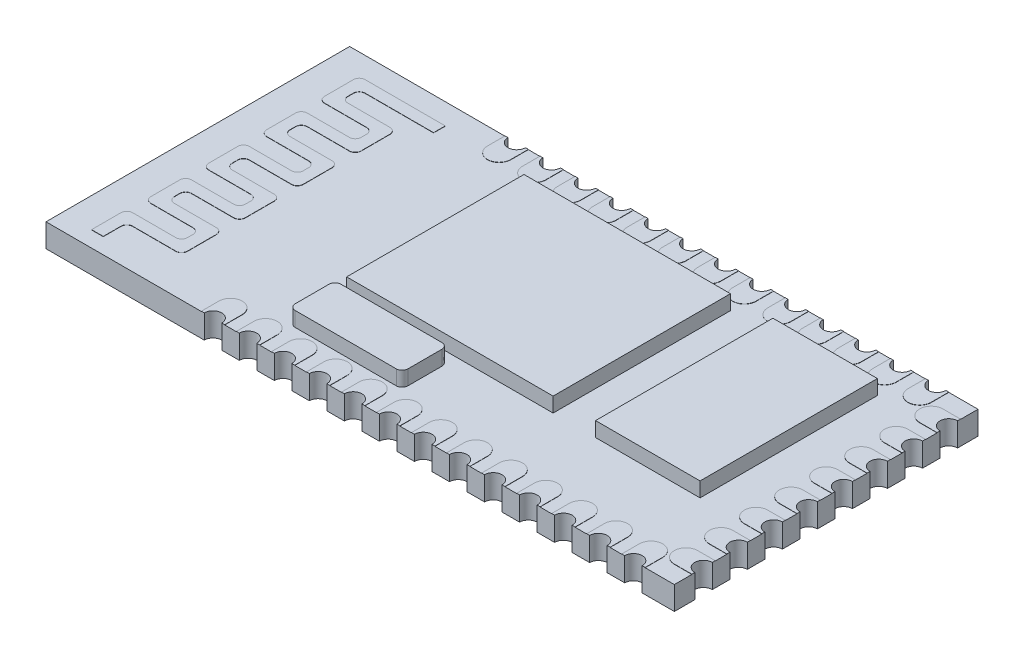
from build123d import *

# Parameters (mm, degrees)
SKETCH1_W           = 26.9
SKETCH1_H           = 13
BOSS_EXTRUDE1_DEPTH = 1
SKETCH2_W           = 4.474027776
SKETCH2_H           = 7.592289559
SKETCH2_W_2         = 8.839594273
BOSS_EXTRUDE2_DEPTH = 0.63
BOSS_EXTRUDE3_DEPTH = 0.01
BOSS_EXTRUDE4_DEPTH = 0.63
BOSS_EXTRUDE5_DEPTH = 0.01
SKETCH7_W           = 22.420690482
SKETCH7_H           = 1.871477004
CUT_EXTRUDE1_DEPTH  = 2.01
SKETCH8_R           = 0.375
CUT_EXTRUDE2_DEPTH  = 2.01
LPATTERN1_COUNT     = 13
LPATTERN1_PITCH     = 1.5
SKETCH9_R           = 0.375
CUT_EXTRUDE3_DEPTH  = 2.01
LPATTERN2_COUNT     = 8
LPATTERN2_PITCH     = 1.5
SCALE1_SCALE        = 1.769


with BuildPart() as part:
    # Sketch1 → Boss-Extrude1 (new body)
    with BuildSketch(Plane(origin=(0, 0, 0), x_dir=(1, 0, 0), z_dir=(0, 1, 0))):
        with Locations((13.45, 6.5)):
            Rectangle(SKETCH1_W, SKETCH1_H)
    extrude(amount=BOSS_EXTRUDE1_DEPTH)

    # Sketch2 → Boss-Extrude2 (add)
    with BuildSketch(Plane(origin=(0, 1, 0), x_dir=(1, 0, 0), z_dir=(0, 1, 0))):
        with Locations((22.000611186, 7.559584322)):
            Rectangle(SKETCH2_W, SKETCH2_H)
        with Locations((13.527073731, 7.559584322)):
            Rectangle(SKETCH2_W_2, SKETCH2_H)
    extrude(amount=BOSS_EXTRUDE2_DEPTH)

    # Sketch3 → Boss-Extrude3 (add)
    with BuildSketch(Plane(origin=(0, 1, 0), x_dir=(1, 0, 0), z_dir=(0, 1, 0))):
        with BuildLine():
            Line((5.001748059, 12.091352807), (1.569925159, 12.091352807))
            ThreePointArc((1.569925159, 12.091352807), (1.393148464, 12.018129502), (1.319925159, 11.841352807))
            Line((1.319925159, 11.841352807), (1.319925159, 10.602651625))
            ThreePointArc((1.319925159, 10.602651625), (1.393148464, 10.42587493), (1.569925159, 10.352651625))
            Line((1.569925159, 10.352651625), (3.374727347, 10.352651625))
            ThreePointArc((3.374727347, 10.352651625), (3.551504042, 10.27942832), (3.624727347, 10.102651625))
            Line((3.624727347, 10.102651625), (3.624727347, 9.863950443))
            ThreePointArc((3.624727347, 9.863950443), (3.551504042, 9.687173748), (3.374727347, 9.613950443))
            Line((3.374727347, 9.613950443), (1.569925159, 9.613950443))
            ThreePointArc((1.569925159, 9.613950443), (1.393148464, 9.540727138), (1.319925159, 9.363950443))
            Line((1.319925159, 9.363950443), (1.319925159, 8.125249261))
            ThreePointArc((1.319925159, 8.125249261), (1.393148464, 7.948472566), (1.569925159, 7.875249261))
            Line((1.569925159, 7.875249261), (3.374727347, 7.875249261))
            ThreePointArc((3.374727347, 7.875249261), (3.551504042, 7.802025956), (3.624727347, 7.625249261))
            Line((3.624727347, 7.625249261), (3.624727347, 7.386548079))
            ThreePointArc((3.624727347, 7.386548079), (3.551504042, 7.209771384), (3.374727347, 7.136548079))
            Line((3.374727347, 7.136548079), (1.569925159, 7.136548079))
            ThreePointArc((1.569925159, 7.136548079), (1.393148464, 7.063324774), (1.319925159, 6.886548079))
            Line((1.319925159, 6.886548079), (1.319925159, 5.647846897))
            ThreePointArc((1.319925159, 5.647846897), (1.393148464, 5.471070202), (1.569925159, 5.397846897))
            Line((1.569925159, 5.397846897), (3.374727347, 5.397846897))
            ThreePointArc((3.374727347, 5.397846897), (3.551504042, 5.324623592), (3.624727347, 5.147846897))
            Line((3.624727347, 5.147846897), (3.624727347, 4.909145715))
            ThreePointArc((3.624727347, 4.909145715), (3.551504042, 4.732369019), (3.374727347, 4.659145715))
            Line((3.374727347, 4.659145715), (1.569925159, 4.659145715))
            ThreePointArc((1.569925159, 4.659145715), (1.393148464, 4.58592241), (1.319925159, 4.409145715))
            Line((1.319925159, 4.409145715), (1.319925159, 3.170444533))
            ThreePointArc((1.319925159, 3.170444533), (1.393148464, 2.993667837), (1.569925159, 2.920444533))
            Line((1.569925159, 2.920444533), (3.374727347, 2.920444533))
            ThreePointArc((3.374727347, 2.920444533), (3.551504042, 2.847221228), (3.624727347, 2.670444533))
            Line((3.624727347, 2.670444533), (3.624727347, 2.431743351))
            ThreePointArc((3.624727347, 2.431743351), (3.551504042, 2.254966655), (3.374727347, 2.181743351))
            Line((3.374727347, 2.181743351), (1.527027373, 2.181743351))
            ThreePointArc((1.527027373, 2.181743351), (1.350250678, 2.108520046), (1.277027373, 1.931743351))
            Line((1.277027373, 1.931743351), (1.277027373, 0.673866206))
            Line((1.277027373, 0.673866206), (1.777027373, 0.673866206))
            Line((1.777027373, 0.673866206), (1.777027373, 1.431743351))
            ThreePointArc((1.777027373, 1.431743351), (1.850250678, 1.608520046), (2.027027373, 1.681743351))
            Line((2.027027373, 1.681743351), (3.874727347, 1.681743351))
            ThreePointArc((3.874727347, 1.681743351), (4.051504042, 1.754966655), (4.124727347, 1.931743351))
            Line((4.124727347, 1.931743351), (4.124727347, 3.170444533))
            ThreePointArc((4.124727347, 3.170444533), (4.051504042, 3.347221228), (3.874727347, 3.420444533))
            Line((3.874727347, 3.420444533), (2.069925159, 3.420444533))
            ThreePointArc((2.069925159, 3.420444533), (1.893148464, 3.493667837), (1.819925159, 3.670444533))
            Line((1.819925159, 3.670444533), (1.819925159, 3.909145715))
            ThreePointArc((1.819925159, 3.909145715), (1.893148464, 4.08592241), (2.069925159, 4.159145715))
            Line((2.069925159, 4.159145715), (3.874727347, 4.159145715))
            ThreePointArc((3.874727347, 4.159145715), (4.051504042, 4.232369019), (4.124727347, 4.409145715))
            Line((4.124727347, 4.409145715), (4.124727347, 5.647846897))
            ThreePointArc((4.124727347, 5.647846897), (4.051504042, 5.824623592), (3.874727347, 5.897846897))
            Line((3.874727347, 5.897846897), (2.069925159, 5.897846897))
            ThreePointArc((2.069925159, 5.897846897), (1.893148464, 5.971070202), (1.819925159, 6.147846897))
            Line((1.819925159, 6.147846897), (1.819925159, 6.386548079))
            ThreePointArc((1.819925159, 6.386548079), (1.893148464, 6.563324774), (2.069925159, 6.636548079))
            Line((2.069925159, 6.636548079), (3.874727347, 6.636548079))
            ThreePointArc((3.874727347, 6.636548079), (4.051504042, 6.709771384), (4.124727347, 6.886548079))
            Line((4.124727347, 6.886548079), (4.124727347, 8.125249261))
            ThreePointArc((4.124727347, 8.125249261), (4.051504042, 8.302025956), (3.874727347, 8.375249261))
            Line((3.874727347, 8.375249261), (2.069925159, 8.375249261))
            ThreePointArc((2.069925159, 8.375249261), (1.893148464, 8.448472566), (1.819925159, 8.625249261))
            Line((1.819925159, 8.625249261), (1.819925159, 8.863950443))
            ThreePointArc((1.819925159, 8.863950443), (1.893148464, 9.040727138), (2.069925159, 9.113950443))
            Line((2.069925159, 9.113950443), (3.874727347, 9.113950443))
            ThreePointArc((3.874727347, 9.113950443), (4.051504042, 9.187173748), (4.124727347, 9.363950443))
            Line((4.124727347, 9.363950443), (4.124727347, 10.602651625))
            ThreePointArc((4.124727347, 10.602651625), (4.051504042, 10.77942832), (3.874727347, 10.852651625))
            Line((3.874727347, 10.852651625), (2.069925159, 10.852651625))
            ThreePointArc((2.069925159, 10.852651625), (1.893148464, 10.92587493), (1.819925159, 11.102651625))
            Line((1.819925159, 11.102651625), (1.819925159, 11.341352807))
            ThreePointArc((1.819925159, 11.341352807), (1.893148464, 11.518129502), (2.069925159, 11.591352807))
            Line((2.069925159, 11.591352807), (5.001748059, 11.591352807))
            Line((5.001748059, 11.591352807), (5.001748059, 12.091352807))
        make_face()
    extrude(amount=BOSS_EXTRUDE3_DEPTH)

    # Sketch4 → Boss-Extrude4 (add)
    with BuildSketch(Plane(origin=(0, 1, 0), x_dir=(1, 0, 0), z_dir=(0, 1, 0))):
        with BuildLine():
            Line((9.253087544, 3.367848777), (13.579614478, 3.367848777))
            ThreePointArc((13.579614478, 3.367848777), (13.756391173, 3.294625473), (13.829614478, 3.117848777))
            Line((13.829614478, 3.117848777), (13.829614478, 1.665545748))
            ThreePointArc((13.829614478, 1.665545748), (13.756391173, 1.488769052), (13.579614478, 1.415545748))
            Line((13.579614478, 1.415545748), (9.253087544, 1.415545748))
            ThreePointArc((9.253087544, 1.415545748), (9.076310848, 1.488769052), (9.003087544, 1.665545748))
            Line((9.003087544, 1.665545748), (9.003087544, 3.117848777))
            ThreePointArc((9.003087544, 3.117848777), (9.076310848, 3.294625473), (9.253087544, 3.367848777))
        make_face()
    extrude(amount=BOSS_EXTRUDE4_DEPTH)

    # Sketch5 → Boss-Extrude5 (add)
    with BuildSketch(Plane(origin=(0, 1, 0), x_dir=(1, 0, 0), z_dir=(0, 1, 0))):
        with BuildLine():
            Line((26.15, 12.25), (28.15, 12.25))
            ThreePointArc((28.15, 12.25), (28.65, 11.75), (28.15, 11.25))
            Line((28.15, 11.25), (26.15, 11.25))
            ThreePointArc((26.15, 11.25), (25.65, 11.75), (26.15, 12.25))
        make_face()
        with BuildLine():
            Line((26.15, 10.75), (28.15, 10.75))
            ThreePointArc((28.15, 10.75), (28.65, 10.25), (28.15, 9.75))
            Line((28.15, 9.75), (26.15, 9.75))
            ThreePointArc((26.15, 9.75), (25.65, 10.25), (26.15, 10.75))
        make_face()
        with BuildLine():
            Line((26.15, 9.25), (28.15, 9.25))
            ThreePointArc((28.15, 9.25), (28.65, 8.75), (28.15, 8.25))
            Line((28.15, 8.25), (26.15, 8.25))
            ThreePointArc((26.15, 8.25), (25.65, 8.75), (26.15, 9.25))
        make_face()
        with BuildLine():
            Line((26.15, 7.75), (28.15, 7.75))
            ThreePointArc((28.15, 7.75), (28.65, 7.25), (28.15, 6.75))
            Line((28.15, 6.75), (26.15, 6.75))
            ThreePointArc((26.15, 6.75), (25.65, 7.25), (26.15, 7.75))
        make_face()
        with BuildLine():
            Line((26.15, 6.25), (28.15, 6.25))
            ThreePointArc((28.15, 6.25), (28.65, 5.75), (28.15, 5.25))
            Line((28.15, 5.25), (26.15, 5.25))
            ThreePointArc((26.15, 5.25), (25.65, 5.75), (26.15, 6.25))
        make_face()
        with BuildLine():
            Line((26.15, 4.75), (28.15, 4.75))
            ThreePointArc((28.15, 4.75), (28.65, 4.25), (28.15, 3.75))
            Line((28.15, 3.75), (26.15, 3.75))
            ThreePointArc((26.15, 3.75), (25.65, 4.25), (26.15, 4.75))
        make_face()
        with BuildLine():
            Line((26.15, 3.25), (28.15, 3.25))
            ThreePointArc((28.15, 3.25), (28.65, 2.75), (28.15, 2.25))
            Line((28.15, 2.25), (26.15, 2.25))
            ThreePointArc((26.15, 2.25), (25.65, 2.75), (26.15, 3.25))
        make_face()
        with BuildLine():
            Line((26.15, 1.75), (28.15, 1.75))
            ThreePointArc((28.15, 1.75), (28.65, 1.25), (28.15, 0.75))
            Line((28.15, 0.75), (26.15, 0.75))
            ThreePointArc((26.15, 0.75), (25.65, 1.25), (26.15, 1.75))
        make_face()
        with BuildLine():
            Line((24.65, 12.25), (24.65, 14.25))
            ThreePointArc((24.65, 14.25), (25.15, 14.75), (25.65, 14.25))
            Line((25.65, 14.25), (25.65, 12.25))
            ThreePointArc((25.65, 12.25), (25.15, 11.75), (24.65, 12.25))
        make_face()
        with BuildLine():
            Line((23.15, 12.25), (23.15, 14.25))
            ThreePointArc((23.15, 14.25), (23.65, 14.75), (24.15, 14.25))
            Line((24.15, 14.25), (24.15, 12.25))
            ThreePointArc((24.15, 12.25), (23.65, 11.75), (23.15, 12.25))
        make_face()
        with BuildLine():
            Line((21.65, 12.25), (21.65, 14.25))
            ThreePointArc((21.65, 14.25), (22.15, 14.75), (22.65, 14.25))
            Line((22.65, 14.25), (22.65, 12.25))
            ThreePointArc((22.65, 12.25), (22.15, 11.75), (21.65, 12.25))
        make_face()
        with BuildLine():
            Line((20.15, 12.25), (20.15, 14.25))
            ThreePointArc((20.15, 14.25), (20.65, 14.75), (21.15, 14.25))
            Line((21.15, 14.25), (21.15, 12.25))
            ThreePointArc((21.15, 12.25), (20.65, 11.75), (20.15, 12.25))
        make_face()
        with BuildLine():
            Line((18.65, 12.25), (18.65, 14.25))
            ThreePointArc((18.65, 14.25), (19.15, 14.75), (19.65, 14.25))
            Line((19.65, 14.25), (19.65, 12.25))
            ThreePointArc((19.65, 12.25), (19.15, 11.75), (18.65, 12.25))
        make_face()
        with BuildLine():
            Line((17.15, 12.25), (17.15, 14.25))
            ThreePointArc((17.15, 14.25), (17.65, 14.75), (18.15, 14.25))
            Line((18.15, 14.25), (18.15, 12.25))
            ThreePointArc((18.15, 12.25), (17.65, 11.75), (17.15, 12.25))
        make_face()
        with BuildLine():
            Line((15.65, 12.25), (15.65, 14.25))
            ThreePointArc((15.65, 14.25), (16.15, 14.75), (16.65, 14.25))
            Line((16.65, 14.25), (16.65, 12.25))
            ThreePointArc((16.65, 12.25), (16.15, 11.75), (15.65, 12.25))
        make_face()
        with BuildLine():
            Line((14.15, 12.25), (14.15, 14.25))
            ThreePointArc((14.15, 14.25), (14.65, 14.75), (15.15, 14.25))
            Line((15.15, 14.25), (15.15, 12.25))
            ThreePointArc((15.15, 12.25), (14.65, 11.75), (14.15, 12.25))
        make_face()
        with BuildLine():
            Line((12.65, 12.25), (12.65, 14.25))
            ThreePointArc((12.65, 14.25), (13.15, 14.75), (13.65, 14.25))
            Line((13.65, 14.25), (13.65, 12.25))
            ThreePointArc((13.65, 12.25), (13.15, 11.75), (12.65, 12.25))
        make_face()
        with BuildLine():
            Line((11.15, 12.25), (11.15, 14.25))
            ThreePointArc((11.15, 14.25), (11.65, 14.75), (12.15, 14.25))
            Line((12.15, 14.25), (12.15, 12.25))
            ThreePointArc((12.15, 12.25), (11.65, 11.75), (11.15, 12.25))
        make_face()
        with BuildLine():
            Line((9.65, 12.25), (9.65, 14.25))
            ThreePointArc((9.65, 14.25), (10.15, 14.75), (10.65, 14.25))
            Line((10.65, 14.25), (10.65, 12.25))
            ThreePointArc((10.65, 12.25), (10.15, 11.75), (9.65, 12.25))
        make_face()
        with BuildLine():
            Line((8.15, 12.25), (8.15, 14.25))
            ThreePointArc((8.15, 14.25), (8.65, 14.75), (9.15, 14.25))
            Line((9.15, 14.25), (9.15, 12.25))
            ThreePointArc((9.15, 12.25), (8.65, 11.75), (8.15, 12.25))
        make_face()
        with BuildLine():
            Line((6.65, 12.25), (6.65, 14.25))
            ThreePointArc((6.65, 14.25), (7.15, 14.75), (7.65, 14.25))
            Line((7.65, 14.25), (7.65, 12.25))
            ThreePointArc((7.65, 12.25), (7.15, 11.75), (6.65, 12.25))
        make_face()
        with BuildLine():
            Line((24.65, 0.75), (24.65, -1.25))
            ThreePointArc((24.65, -1.25), (25.15, -1.75), (25.65, -1.25))
            Line((25.65, -1.25), (25.65, 0.75))
            ThreePointArc((25.65, 0.75), (25.15, 1.25), (24.65, 0.75))
        make_face()
        with BuildLine():
            Line((23.15, 0.75), (23.15, -1.25))
            ThreePointArc((23.15, -1.25), (23.65, -1.75), (24.15, -1.25))
            Line((24.15, -1.25), (24.15, 0.75))
            ThreePointArc((24.15, 0.75), (23.65, 1.25), (23.15, 0.75))
        make_face()
        with BuildLine():
            Line((21.65, 0.75), (21.65, -1.25))
            ThreePointArc((21.65, -1.25), (22.15, -1.75), (22.65, -1.25))
            Line((22.65, -1.25), (22.65, 0.75))
            ThreePointArc((22.65, 0.75), (22.15, 1.25), (21.65, 0.75))
        make_face()
        with BuildLine():
            Line((20.15, 0.75), (20.15, -1.25))
            ThreePointArc((20.15, -1.25), (20.65, -1.75), (21.15, -1.25))
            Line((21.15, -1.25), (21.15, 0.75))
            ThreePointArc((21.15, 0.75), (20.65, 1.25), (20.15, 0.75))
        make_face()
        with BuildLine():
            Line((18.65, 0.75), (18.65, -1.25))
            ThreePointArc((18.65, -1.25), (19.15, -1.75), (19.65, -1.25))
            Line((19.65, -1.25), (19.65, 0.75))
            ThreePointArc((19.65, 0.75), (19.15, 1.25), (18.65, 0.75))
        make_face()
        with BuildLine():
            Line((17.15, 0.75), (17.15, -1.25))
            ThreePointArc((17.15, -1.25), (17.65, -1.75), (18.15, -1.25))
            Line((18.15, -1.25), (18.15, 0.75))
            ThreePointArc((18.15, 0.75), (17.65, 1.25), (17.15, 0.75))
        make_face()
        with BuildLine():
            Line((15.65, 0.75), (15.65, -1.25))
            ThreePointArc((15.65, -1.25), (16.15, -1.75), (16.65, -1.25))
            Line((16.65, -1.25), (16.65, 0.75))
            ThreePointArc((16.65, 0.75), (16.15, 1.25), (15.65, 0.75))
        make_face()
        with BuildLine():
            Line((14.15, 0.75), (14.15, -1.25))
            ThreePointArc((14.15, -1.25), (14.65, -1.75), (15.15, -1.25))
            Line((15.15, -1.25), (15.15, 0.75))
            ThreePointArc((15.15, 0.75), (14.65, 1.25), (14.15, 0.75))
        make_face()
        with BuildLine():
            Line((12.65, 0.75), (12.65, -1.25))
            ThreePointArc((12.65, -1.25), (13.15, -1.75), (13.65, -1.25))
            Line((13.65, -1.25), (13.65, 0.75))
            ThreePointArc((13.65, 0.75), (13.15, 1.25), (12.65, 0.75))
        make_face()
        with BuildLine():
            Line((11.15, 0.75), (11.15, -1.25))
            ThreePointArc((11.15, -1.25), (11.65, -1.75), (12.15, -1.25))
            Line((12.15, -1.25), (12.15, 0.75))
            ThreePointArc((12.15, 0.75), (11.65, 1.25), (11.15, 0.75))
        make_face()
        with BuildLine():
            Line((9.65, 0.75), (9.65, -1.25))
            ThreePointArc((9.65, -1.25), (10.15, -1.75), (10.65, -1.25))
            Line((10.65, -1.25), (10.65, 0.75))
            ThreePointArc((10.65, 0.75), (10.15, 1.25), (9.65, 0.75))
        make_face()
        with BuildLine():
            Line((8.15, 0.75), (8.15, -1.25))
            ThreePointArc((8.15, -1.25), (8.65, -1.75), (9.15, -1.25))
            Line((9.15, -1.25), (9.15, 0.75))
            ThreePointArc((9.15, 0.75), (8.65, 1.25), (8.15, 0.75))
        make_face()
        with BuildLine():
            Line((6.65, 0.75), (6.65, -1.25))
            ThreePointArc((6.65, -1.25), (7.15, -1.75), (7.65, -1.25))
            Line((7.65, -1.25), (7.65, 0.75))
            ThreePointArc((7.65, 0.75), (7.15, 1.25), (6.65, 0.75))
        make_face()
    extrude(amount=BOSS_EXTRUDE5_DEPTH)

    # Sketch7 → Cut-Extrude1 (cut, through all)
    with BuildSketch(Plane(origin=(0, 1.01, 0), x_dir=(1, 0, 0), z_dir=(0, 1, 0))):
        with BuildLine():
            Line((7.65, 14.25), (7.65, 13))
            Line((7.65, 13), (26.9, 13))
            Line((26.9, 13), (26.9, 15.004533592))
            Line((26.9, 15.004533592), (6.65, 15.004533592))
            Line((6.65, 15.004533592), (6.65, 14.25))
            ThreePointArc((6.65, 14.25), (7.15, 14.75), (7.65, 14.25))
        make_face()
        Polygon((26.9, 15.004533592), (26.9, 13), (26.9, 0), (29.070690482, 0), (29.070690482, 15.004533592), align=None)
        with BuildLine():
            Line((6.65, 14.25), (6.65, 13))
            Line((6.65, 13), (7.65, 13))
            Line((7.65, 13), (7.65, 14.25))
            ThreePointArc((7.65, 14.25), (7.15, 14.75), (6.65, 14.25))
        make_face()
        with Locations((17.860345241, -0.935738502)):
            Rectangle(SKETCH7_W, SKETCH7_H)
    extrude(amount=-CUT_EXTRUDE1_DEPTH, mode=Mode.SUBTRACT)

    # Sketch8 → Cut-Extrude2 (cut, through all)
    with BuildSketch(Plane(origin=(0, 1.01, 0), x_dir=(1, 0, 0), z_dir=(0, 1, 0))):
        with Locations((7.15, 13)):
            Circle(SKETCH8_R)
        with Locations((7.15, 0)):
            Circle(SKETCH8_R)
    cut_extrude2 = extrude(amount=-CUT_EXTRUDE2_DEPTH, mode=Mode.SUBTRACT)

    # LPattern1: Cut-Extrude2 ×13
    with Locations(*[(i * LPATTERN1_PITCH, 0, 0) for i in range(1, LPATTERN1_COUNT)]):
        add(cut_extrude2, mode=Mode.SUBTRACT)

    # Sketch9 → Cut-Extrude3 (cut, through all)
    with BuildSketch(Plane(origin=(0, 1.01, 0), x_dir=(1, 0, 0), z_dir=(0, 1, 0))):
        with Locations((26.9, 11.75)):
            Circle(SKETCH9_R)
    cut_extrude3 = extrude(amount=-CUT_EXTRUDE3_DEPTH, mode=Mode.SUBTRACT)

    # LPattern2: Cut-Extrude3 ×8
    with Locations(*[(0, 0, i * LPATTERN2_PITCH) for i in range(1, LPATTERN2_COUNT)]):
        add(cut_extrude3, mode=Mode.SUBTRACT)


with BuildPart() as part_1:
    # Scale1: scaled about (13.777615626, 0.638149459, -6.604987897)
    add(part.part.scale(SCALE1_SCALE).moved(Location((-10.594986416, -0.490736934, 5.079235693))))


solid = part_1.part
